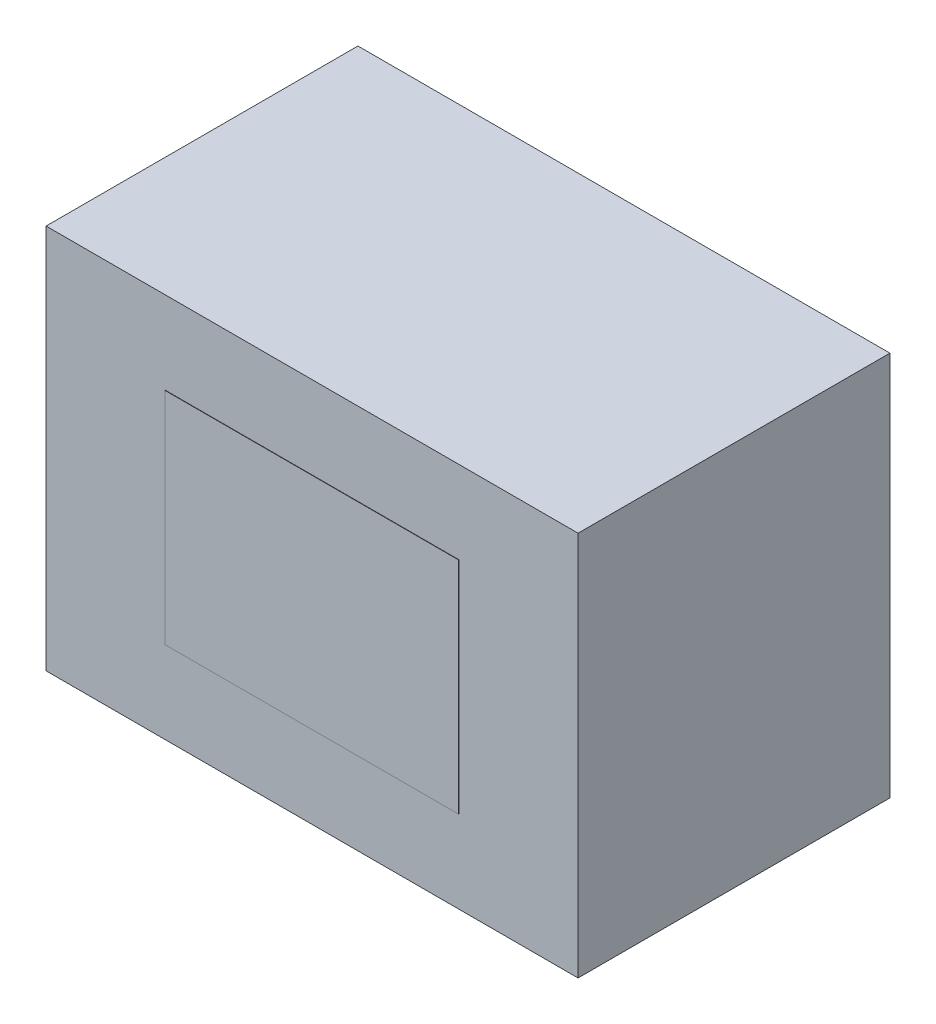
from build123d import *

# Parameters (mm, degrees)
SKETCH1_W           = 177.8
SKETCH1_H           = 127
BOSS_EXTRUDE1_DEPTH = 101.6
MOVE_FACE1_BY       = 3.175
MOVE_FACE1_2_BY     = 3.175
MOVE_FACE1_3_BY     = 3.175
MOVE_FACE1_4_BY     = 3.175
MOVE_FACE1_5_BY     = 3.175
MOVE_FACE1_6_BY     = 3.175
SKETCH2_W           = 101.6
SKETCH2_H           = 76.2
BOSS_EXTRUDE2_DEPTH = 0.127


with BuildPart() as part:
    # Sketch1 → Boss-Extrude1 (new body)
    with BuildSketch(Plane.XY):
        Rectangle(SKETCH1_W, SKETCH1_H)
    extrude(amount=BOSS_EXTRUDE1_DEPTH)

    # Move Face1: a face moved outward by 3.175
    extrude(part.faces().sort_by_distance((0, -63.5, 50.8))[0], amount=MOVE_FACE1_BY, dir=(0, -1, 0))

    # Move Face1 2: a face moved outward by 3.175
    extrude(part.faces().sort_by_distance((0, 0, 0))[0], amount=MOVE_FACE1_2_BY, dir=(0, 0, -1))

    # Move Face1 3: a face moved outward by 3.175
    extrude(part.faces().sort_by_distance((-88.9, 0, 50.8))[0], amount=MOVE_FACE1_3_BY, dir=(-1, 0, 0))

    # Move Face1 4: a face moved outward by 3.175
    extrude(part.faces().sort_by_distance((88.9, 0, 50.8))[0], amount=MOVE_FACE1_4_BY, dir=(1, 0, 0))

    # Move Face1 5: a face moved outward by 3.175
    extrude(part.faces().sort_by_distance((0, 63.5, 50.8))[0], amount=MOVE_FACE1_5_BY, dir=(0, 1, 0))

    # Move Face1 6: a face moved outward by 3.175
    extrude(part.faces().sort_by_distance((0, 0, 101.6))[0], amount=MOVE_FACE1_6_BY, dir=(0, 0, 1))

    # Sketch2 → Boss-Extrude2 (add)
    with BuildSketch(Plane.XY.offset(104.775)):
        Rectangle(SKETCH2_W, SKETCH2_H)
    extrude(amount=BOSS_EXTRUDE2_DEPTH)


solid = part.part
